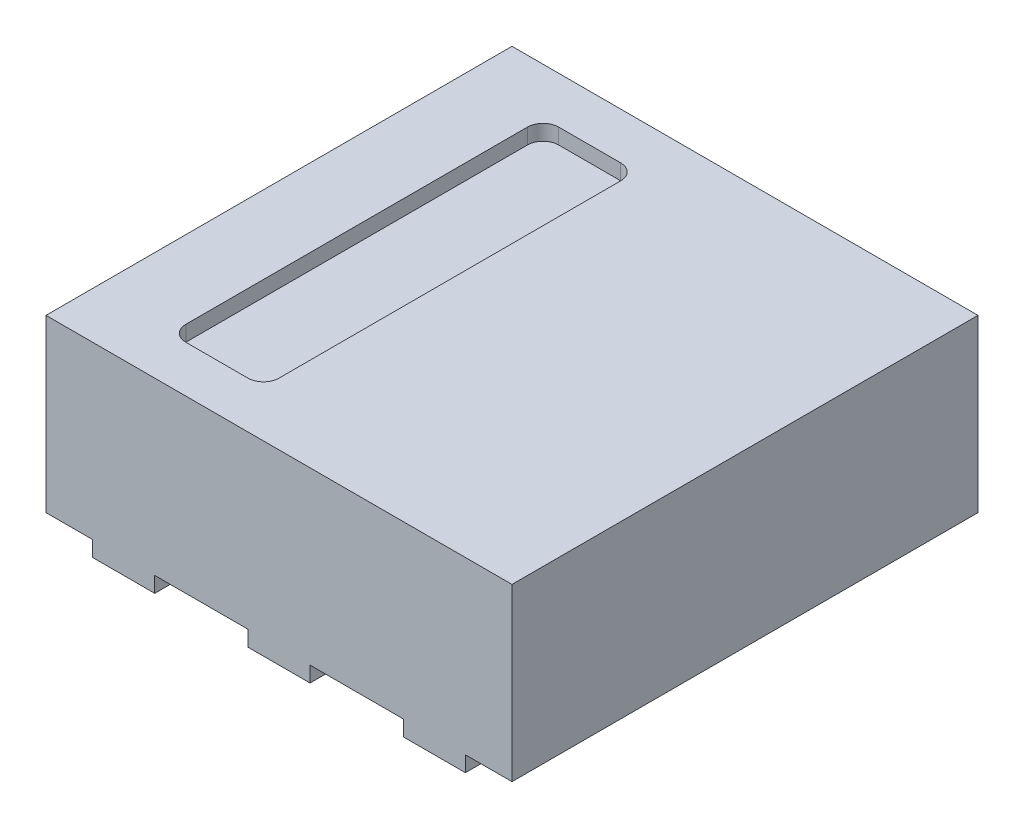
from build123d import *

# Parameters (mm, degrees)
SKETCH_1_W          = 3
SKETCH_1_H          = 3
EXTRUDE_1_DEPTH     = 1.1
CUT_EXTRUDE_1_DEPTH = 0.1
SKETCH_3_W          = 0.4
SKETCH_3_H          = 0.4
EXTRUDE_2_DEPTH     = 0.1


with BuildPart() as part:
    # Эскиз1 → Бобышка-Вытянуть1 (new body)
    with BuildSketch(Plane(origin=(0, 0, 0), x_dir=(1, 0, 0), z_dir=(0, 1, 0))):
        Rectangle(SKETCH_1_W, SKETCH_1_H)
    extrude(amount=EXTRUDE_1_DEPTH)

    # Эскиз2 → Вырез-Вытянуть1 (cut)
    with BuildSketch(Plane(origin=(0, 1.1, 0), x_dir=(1, 0, 0), z_dir=(0, 1, 0))):
        with BuildLine():
            Line((-0.9, 1.2), (-0.5, 1.2))
            ThreePointArc((-0.5, 1.2), (-0.429289322, 1.170710678), (-0.4, 1.1))
            Line((-0.4, 1.1), (-0.4, -1.1))
            ThreePointArc((-0.4, -1.1), (-0.429289322, -1.170710678), (-0.5, -1.2))
            Line((-0.5, -1.2), (-0.9, -1.2))
            ThreePointArc((-0.9, -1.2), (-0.970710678, -1.170710678), (-1, -1.1))
            Line((-1, -1.1), (-1, 1.1))
            ThreePointArc((-1, 1.1), (-0.970710678, 1.170710678), (-0.9, 1.2))
        make_face()
    extrude(amount=-CUT_EXTRUDE_1_DEPTH, mode=Mode.SUBTRACT)

    # Эскиз3 → Бобышка-Вытянуть2 (add)
    with BuildSketch(Plane.XZ):
        Polygon((1.2, -0.75), (-1.2, -0.75), (-1.2, 0.35), (-0.8, 0.75), (1.2, 0.75), align=None)
        with Locations((1, -1.3)):
            Rectangle(SKETCH_3_W, SKETCH_3_H)
        with Locations((0, -1.3)):
            Rectangle(SKETCH_3_W, SKETCH_3_H)
        with Locations((-1, -1.3)):
            Rectangle(SKETCH_3_W, SKETCH_3_H)
        with Locations((1, 1.3)):
            Rectangle(SKETCH_3_W, SKETCH_3_H)
        with Locations((0, 1.3)):
            Rectangle(SKETCH_3_W, SKETCH_3_H)
        with Locations((-1, 1.3)):
            Rectangle(SKETCH_3_W, SKETCH_3_H)
    extrude(amount=EXTRUDE_2_DEPTH)


solid = part.part
